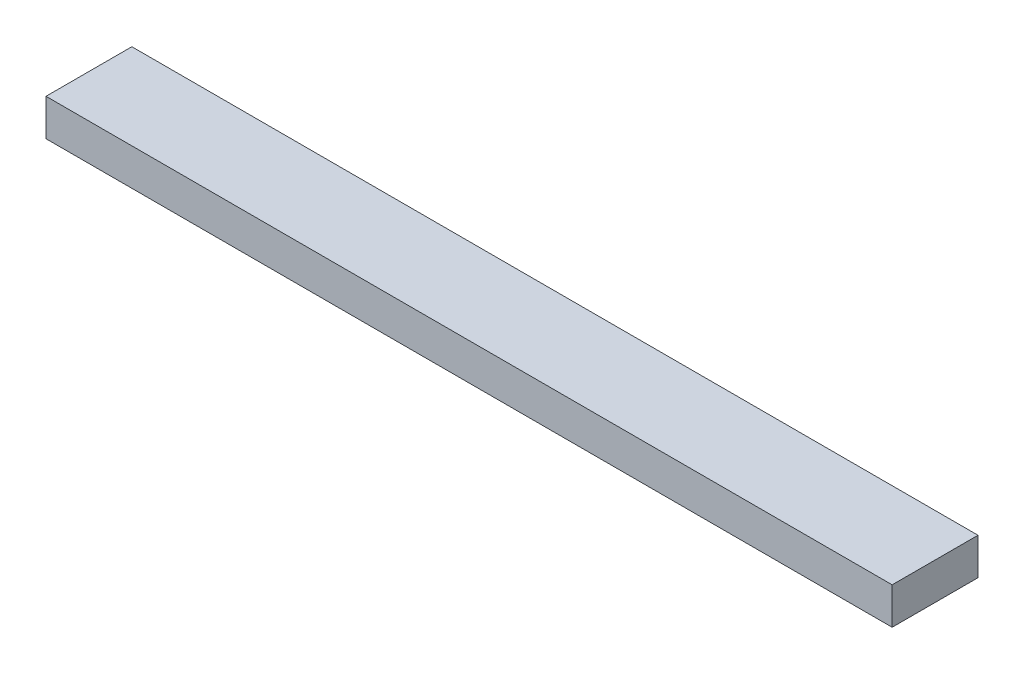
from build123d import *

# Parameters (mm, degrees)
SKETCH1_W           = 876.3
SKETCH1_H           = 88.9
BOSS_EXTRUDE1_DEPTH = 38.1


with BuildPart() as part:
    # Sketch1 → Boss-Extrude1 (new body)
    with BuildSketch(Plane(origin=(0, 0, 0), x_dir=(1, 0, 0), z_dir=(0, 1, 0))):
        with Locations((438.15, 44.45)):
            Rectangle(SKETCH1_W, SKETCH1_H)
    extrude(amount=BOSS_EXTRUDE1_DEPTH)


solid = part.part
